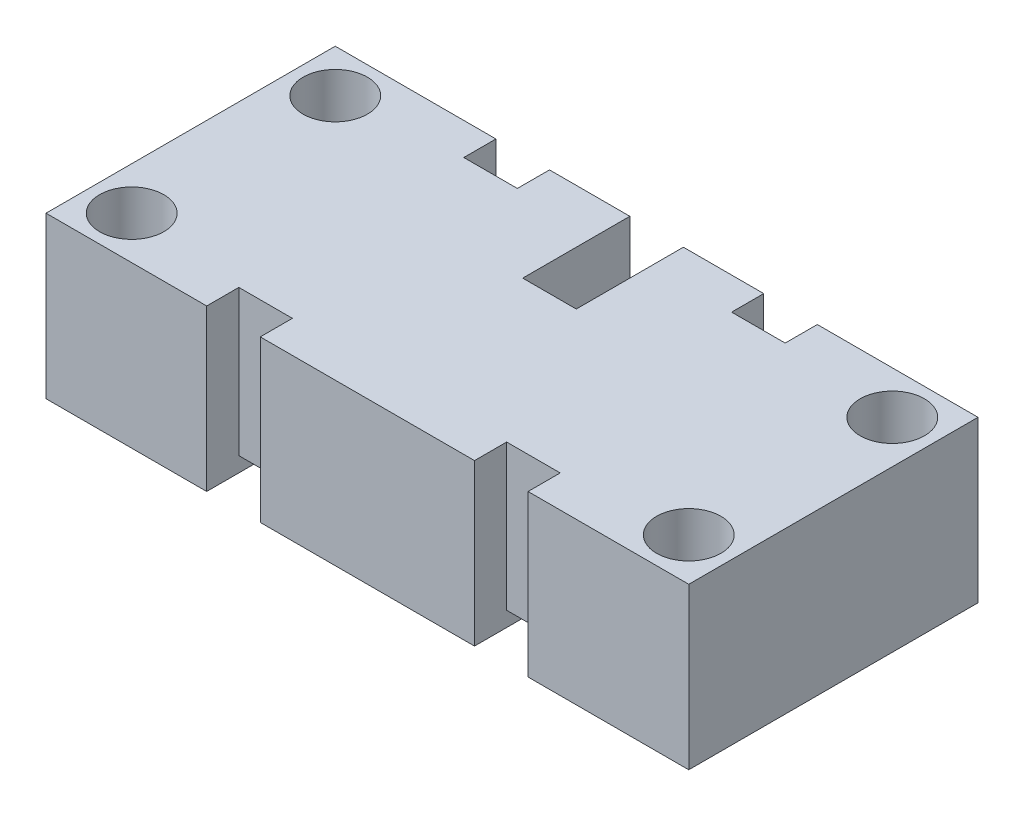
from build123d import *

# Parameters (mm, degrees)
SKETCH1_R           = 3.81
BOSS_EXTRUDE1_DEPTH = 19.05
SKETCH1_3_R         = 3.81
SKETCH1_3_R_2       = 2.159
BOSS_EXTRUDE2_DEPTH = 2.54
SKETCH2_W           = 6.35
SKETCH2_H           = 1.778
CUT_EXTRUDE2_DEPTH  = 60.587802913


with BuildPart() as part:
    # Sketch1 → Boss-Extrude1 (new body)
    with BuildSketch(Plane(origin=(0, 0, 0), x_dir=(1, 0, 0), z_dir=(0, 1, 0))):
        Polygon((-12.294680851, 17.581843972), (-31.344680851, 17.581843972), (-31.344680851, -16.708156028), (-12.294680851, -16.708156028), (-12.294680851, -12.898156028), (-5.944680851, -12.898156028), (-5.944680851, -16.708156028), (19.455319149, -16.708156028), (19.455319149, -12.898156028), (25.805319149, -12.898156028), (25.805319149, -16.708156028), (44.855319149, -16.708156028), (44.855319149, 17.581843972), (25.805319149, 17.581843972), (25.805319149, 13.771843972), (19.455319149, 13.771843972), (19.455319149, 17.581843972), (9.930319149, 17.581843972), (9.930319149, 4.881843972), (3.580319149, 4.881843972), (3.580319149, 17.581843972), (-5.944680851, 17.581843972), (-5.944680851, 13.771843972), (-12.294680851, 13.771843972), align=None)
        with Locations((-26.264680851, 12.501843972)):
            Circle(SKETCH1_R, mode=Mode.SUBTRACT)
        with Locations((39.775319149, 12.501843972)):
            Circle(SKETCH1_R, mode=Mode.SUBTRACT)
        with Locations((39.775319149, -11.628156028)):
            Circle(SKETCH1_R, mode=Mode.SUBTRACT)
        with Locations((-26.264680851, -11.628156028)):
            Circle(SKETCH1_R, mode=Mode.SUBTRACT)
    extrude(amount=BOSS_EXTRUDE1_DEPTH)

    # Sketch1_3 → Boss-Extrude2 (add)
    # profile 1 of 4: a face of its own
    with BuildSketch(Plane(origin=(0, 0, 0), x_dir=(1, 0, 0), z_dir=(0, 1, 0))):
        with Locations((-26.264680851, 12.501843972)):
            Circle(SKETCH1_3_R)
        with Locations((-26.264680851, 12.501843972)):
            Circle(SKETCH1_3_R_2, mode=Mode.SUBTRACT)
    # profile 2 of 4: a face of its own
    with BuildSketch(Plane(origin=(0, 0, 0), x_dir=(1, 0, 0), z_dir=(0, 1, 0))):
        with Locations((39.775319149, 12.501843972)):
            Circle(SKETCH1_3_R)
        with Locations((39.775319149, 12.501843972)):
            Circle(SKETCH1_3_R_2, mode=Mode.SUBTRACT)
    # profile 3 of 4: a face of its own
    with BuildSketch(Plane(origin=(0, 0, 0), x_dir=(1, 0, 0), z_dir=(0, 1, 0))):
        with Locations((-26.264680851, -11.628156028)):
            Circle(SKETCH1_3_R)
        with Locations((-26.264680851, -11.628156028)):
            Circle(SKETCH1_3_R_2, mode=Mode.SUBTRACT)
    # profile 4 of 4: a face of its own
    with BuildSketch(Plane(origin=(0, 0, 0), x_dir=(1, 0, 0), z_dir=(0, 1, 0))):
        with Locations((39.775319149, -11.628156028)):
            Circle(SKETCH1_3_R)
        with Locations((39.775319149, -11.628156028)):
            Circle(SKETCH1_3_R_2, mode=Mode.SUBTRACT)
    extrude(amount=BOSS_EXTRUDE2_DEPTH)

    # Sketch2 → Cut-Extrude2 (cut, through all)
    with BuildSketch(Plane.XY.offset(16.708156028)):
        with Locations((-9.119680851, 0.889)):
            Rectangle(SKETCH2_W, SKETCH2_H)
        with Locations((22.630319149, 0.889)):
            Rectangle(SKETCH2_W, SKETCH2_H)
    extrude(amount=-CUT_EXTRUDE2_DEPTH, mode=Mode.SUBTRACT)


solid = part.part
